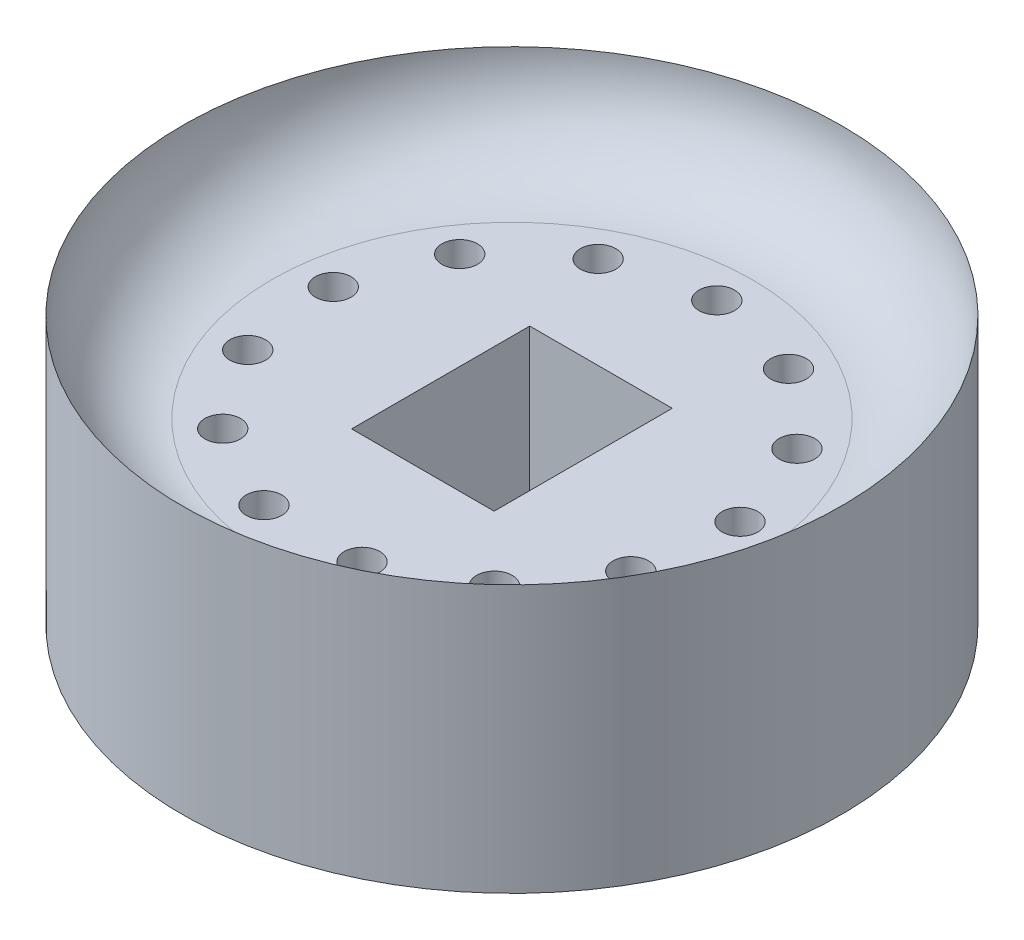
from build123d import *

# Parameters (mm, degrees)
CROQUIS2_R            = 0.5
CROQUIS2_W            = 4
CROQUIS2_H            = 5
CORTAR_EXTRUIR1_DEPTH = 6


with BuildPart() as part:
    # Croquis1 → Revolución1 (revolve)
    with BuildSketch(Plane.XY):
        with BuildLine():
            ThreePointArc((9.25, 7.5), (8.517766953, 5.732233047), (6.75, 5))
            Line((6.75, 5), (0, 5))
            Line((0, 5), (0, 0))
            Line((0, 0), (9.25, 0))
            Line((9.25, 0), (9.25, 7.5))
        make_face()
    revolve(axis=Axis((0, 0, 0), (0, 1, 0)))

    # Croquis2 → Cortar-Extruir1 (cut, through all)
    with BuildSketch(Plane(origin=(0, 5, 0), x_dir=(1, 0, 0), z_dir=(0, 1, 0))):
        with Locations((0, 5.75)):
            Circle(CROQUIS2_R)
        with Locations((2.672158239, 5.091372148)):
            Circle(CROQUIS2_R)
        with Locations((4.732157229, 3.266372294)):
            Circle(CROQUIS2_R)
        with Locations((5.708076026, 0.693085911)):
            Circle(CROQUIS2_R)
        with Locations((5.376343395, -2.0389781)):
            Circle(CROQUIS2_R)
        with Locations((3.812955285, -4.303936802)):
            Circle(CROQUIS2_R)
        with Locations((1.37606507, -5.58291545)):
            Circle(CROQUIS2_R)
        with Locations((-1.37606507, -5.58291545)):
            Circle(CROQUIS2_R)
        with Locations((-3.812955285, -4.303936802)):
            Circle(CROQUIS2_R)
        with Locations((-5.376343395, -2.0389781)):
            Circle(CROQUIS2_R)
        with Locations((-5.708076026, 0.693085911)):
            Circle(CROQUIS2_R)
        with Locations((-4.732157229, 3.266372294)):
            Circle(CROQUIS2_R)
        with Locations((-2.672158239, 5.091372148)):
            Circle(CROQUIS2_R)
        Rectangle(CROQUIS2_W, CROQUIS2_H)
    extrude(amount=-CORTAR_EXTRUIR1_DEPTH, mode=Mode.SUBTRACT)


solid = part.part
